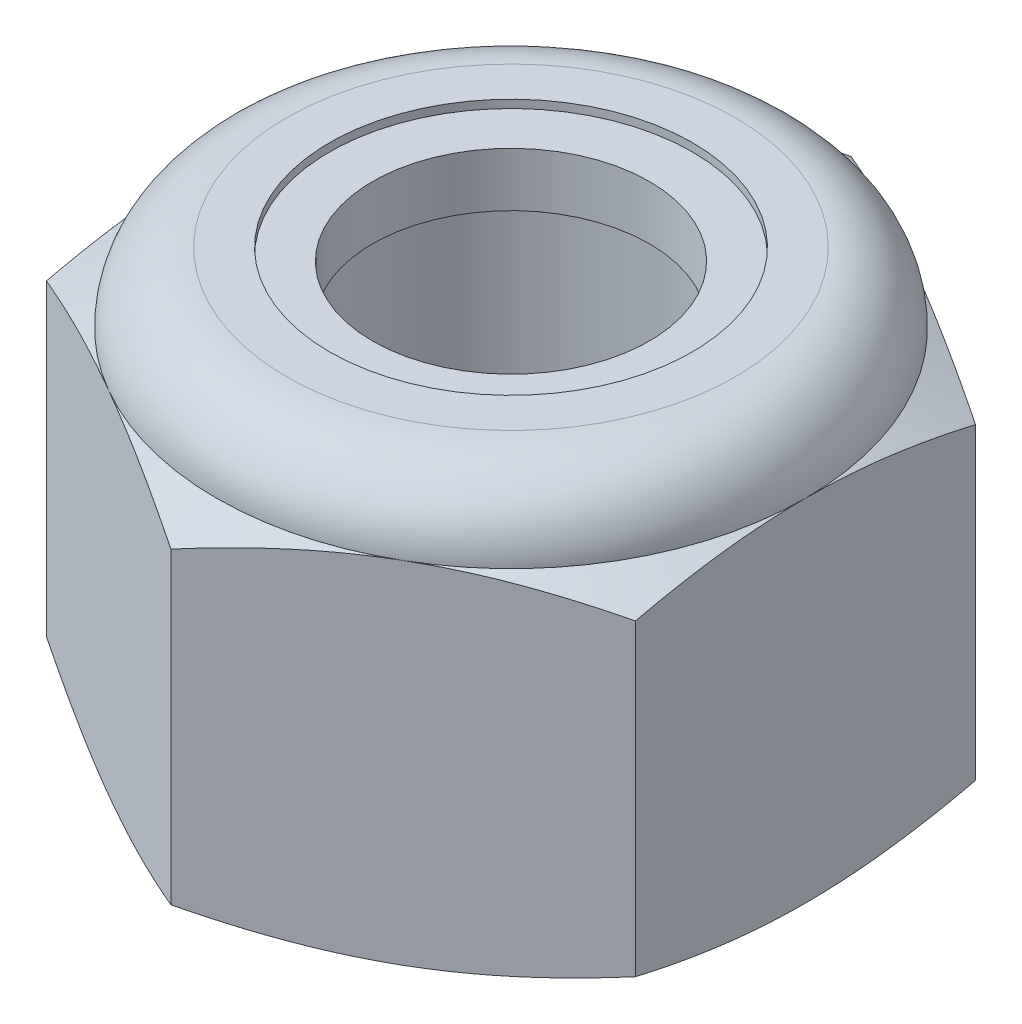
from build123d import *

# Parameters (mm, degrees)
EXTRUDE1_DEPTH = 7.9375
SKETCH2_W      = 3.175
SKETCH2_H      = 7.9375


with BuildPart() as part:
    # Sketch1 → Extrude1 (new body)
    with BuildSketch(Plane(origin=(0, 0, 0), x_dir=(1, 0, 0), z_dir=(0, 1, 0))):
        Polygon((0, 6.415804866), (-5.55625, 3.207902433), (-5.55625, -3.207902433), (0, -6.415804866), (5.55625, -3.207902433), (5.55625, 3.207902433), align=None)
    extrude(amount=EXTRUDE1_DEPTH)


with BuildPart() as body_2:
    # Sketch2 → Revolve1 (revolve)
    with BuildSketch(Plane(origin=(0, 0, 0), x_dir=(0, 0, -1), z_dir=(1, 0, 0))):
        with Locations((1.5875, 3.96875)):
            Rectangle(SKETCH2_W, SKETCH2_H)
    revolve(axis=Axis((0, -3.175, 0), (0, 1, 0)))


with BuildPart() as part_1:
    add(part.part)

    # Combine1: cut body 2
    add(body_2.part, mode=Mode.SUBTRACT)

    # Sketch5 → Cut-Revolve3 (revolve, cut)
    with BuildSketch(Plane(origin=(0, 0, 0), x_dir=(0, 0, -1), z_dir=(1, 0, 0))):
        with BuildLine():
            Line((0, 0), (5.55625, 0))
            Line((5.55625, 0), (6.415804866, 0.400817017))
            Line((6.415804866, 0.400817017), (6.415804866, 6.213766317))
            Line((6.415804866, 6.213766317), (5.55625, 6.614583333))
            ThreePointArc((5.55625, 6.614583333), (5.168776679, 7.550026679), (4.233333333, 7.9375))
            Line((4.233333333, 7.9375), (4.233333333, 9.2075))
            Line((4.233333333, 9.2075), (7.685804866, 9.2075))
            Line((7.685804866, 9.2075), (7.685804866, -1.27))
            Line((7.685804866, -1.27), (0, -1.27))
            Line((0, -1.27), (0, 0))
        make_face()
    revolve(axis=Axis((0, 0, 0), (0, 1, 0)), mode=Mode.SUBTRACT)

    # Sketch6 → Cut-Revolve4 (revolve, cut)
    with BuildSketch(Plane(origin=(0, 0, 0), x_dir=(0, 0, -1), z_dir=(1, 0, 0))):
        with BuildLine():
            Line((0, 6.614583333), (5.40385, 6.614583333))
            ThreePointArc((5.40385, 6.614583333), (5.061013606, 7.442263606), (4.233333333, 7.7851))
            Line((4.233333333, 7.7851), (3.421620845, 7.7851))
            Line((3.421620845, 7.7851), (3.421620845, 9.2075))
            Line((3.421620845, 9.2075), (0, 9.2075))
            Line((0, 9.2075), (0, 6.614583333))
        make_face()
    revolve(axis=Axis((0, 9.2075, 0), (0, 1, 0)), mode=Mode.SUBTRACT)


with BuildPart() as body_2_2:
    # Sketch7 → Revolve2 (revolve)
    with BuildSketch(Plane(origin=(0, 0, 0), x_dir=(0, 0, -1), z_dir=(1, 0, 0))):
        with BuildLine():
            Line((2.609908356, 6.690783333), (5.324993778, 6.690783333))
            ThreePointArc((5.324993778, 6.690783333), (4.979705237, 7.4148695), (4.233333333, 7.7089))
            Line((4.233333333, 7.7089), (2.609908356, 7.7089))
            Line((2.609908356, 7.7089), (2.609908356, 6.690783333))
        make_face()
    revolve(axis=Axis((0, 6.690783333, 0), (0, 1, 0)))


solid = Compound([part_1.part, body_2_2.part])
